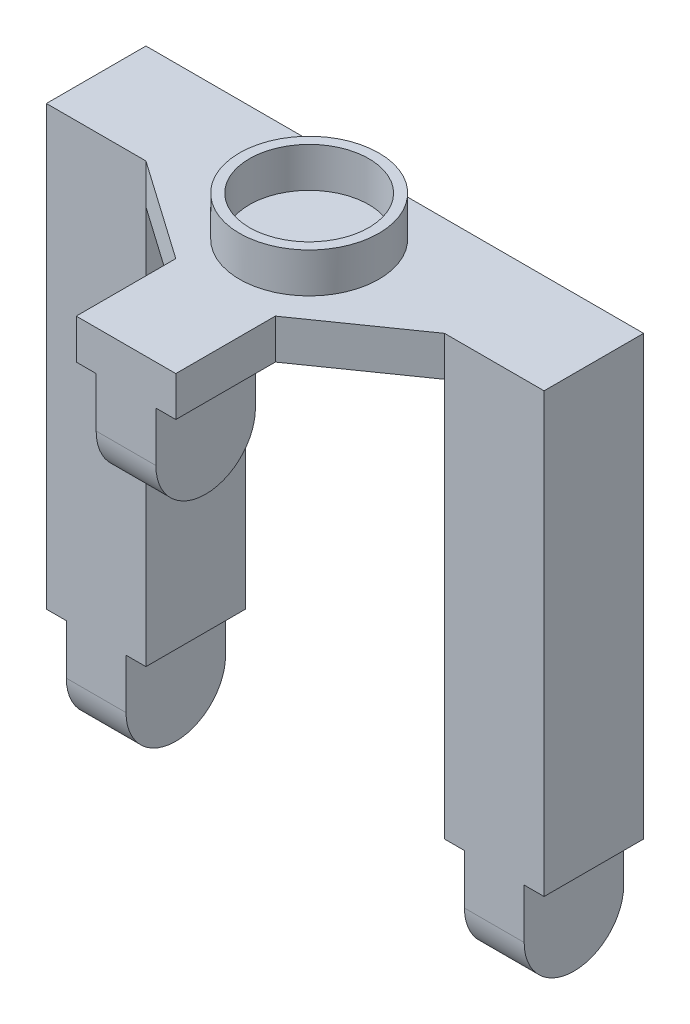
from build123d import *

# Parameters (mm, degrees)
EXTRUDE_1_DEPTH     = 4
SKETCH_1_W          = 10
SKETCH_1_H          = 10
EXTRUDE_2_DEPTH     = 50
SKETCH_6_W          = 10
SKETCH_6_H          = 10
EXTRUDE_4_DEPTH     = 10
SKETCH_7_W          = 2
SKETCH_7_H          = 10
SKETCH_7_W_2        = 4.928830328
SKETCH_7_W_3        = 5.69296793
SKETCH_7_W_4        = 34
CUT_EXTRUDE_3_DEPTH = 28
CUT_EXTRUDE_4_DEPTH = 51
SKETCH_9_R          = 7
SKETCH_9_R_2        = 6
EXTRUDE_5_DEPTH     = 4


with BuildPart() as part:
    # 草图2 → 凸台-拉伸1 (new body)
    with BuildSketch(Plane(origin=(0, 0, 0), x_dir=(1, 0, 0), z_dir=(0, 1, 0))):
        Polygon((-5, -22), (5, -22), (5, -12), (15, -5), (25, -5), (25, 5), (-25, 5), (-25, -5), (-15, -5), (-5, -12), align=None)
    extrude(amount=EXTRUDE_1_DEPTH)

    # 草图1 → 凸台-拉伸2 (add)
    with BuildSketch(Plane(origin=(0, 0, 0), x_dir=(1, 0, 0), z_dir=(0, 1, 0))):
        with Locations((-20, 0)):
            Rectangle(SKETCH_1_W, SKETCH_1_H)
        with Locations((20, 0)):
            Rectangle(SKETCH_1_W, SKETCH_1_H)
    extrude(amount=-EXTRUDE_2_DEPTH)

    # 草图6 → 凸台-拉伸4 (add)
    with BuildSketch(Plane.XZ):
        with Locations((0, 17)):
            Rectangle(SKETCH_6_W, SKETCH_6_H)
    extrude(amount=EXTRUDE_4_DEPTH)

    # 草图7 → 切除-拉伸3 (cut, through all)
    with BuildSketch(Plane(origin=(0, 0, -5), x_dir=(-1, 0, 0), z_dir=(0, 0, -1))):
        with Locations((-24, -45)):
            Rectangle(SKETCH_7_W, SKETCH_7_H)
        with Locations((24, -45)):
            Rectangle(SKETCH_7_W, SKETCH_7_H)
        with Locations((-5.464415164, -5)):
            Rectangle(SKETCH_7_W_2, SKETCH_7_H)
        with Locations((5.846483965, -5)):
            Rectangle(SKETCH_7_W_3, SKETCH_7_H)
        with Locations((0, -45)):
            Rectangle(SKETCH_7_W_4, SKETCH_7_H)
    extrude(amount=-CUT_EXTRUDE_3_DEPTH, mode=Mode.SUBTRACT)

    # 草图8 → 切除-拉伸4 (cut, through all)
    with BuildSketch(Plane(origin=(25, 0, 0), x_dir=(0, 0, -1), z_dir=(1, 0, 0))):
        with BuildLine():
            Line((-22, -5), (-22, -14.409566658))
            Line((-22, -14.409566658), (-12, -14.409566658))
            Line((-12, -14.409566658), (-12, -5))
            ThreePointArc((-12, -5), (-17, -10), (-22, -5))
        make_face()
        with BuildLine():
            Line((-5, -45), (-5, -53.480862615))
            Line((-5, -53.480862615), (5, -53.480862615))
            Line((5, -53.480862615), (5, -45))
            ThreePointArc((5, -45), (0, -50), (-5, -45))
        make_face()
    extrude(amount=-CUT_EXTRUDE_4_DEPTH, mode=Mode.SUBTRACT)

    # 草图9 → 凸台-拉伸5 (add)
    with BuildSketch(Plane(origin=(0, 4, 0), x_dir=(1, 0, 0), z_dir=(0, 1, 0))):
        with Locations((0, -3.6)):
            Circle(SKETCH_9_R)
        with Locations((0, -3.6)):
            Circle(SKETCH_9_R_2, mode=Mode.SUBTRACT)
    extrude(amount=EXTRUDE_5_DEPTH)


solid = part.part
